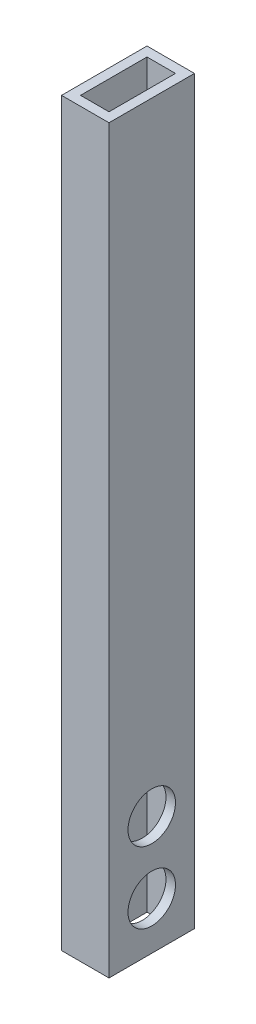
from build123d import *

# Parameters (mm, degrees)
SKETCH1_W           = 10
SKETCH1_H           = 250
BOSS_EXTRUDE1_DEPTH = 18
SHELL1_T            = -2
SKETCH3_R           = 5
CUT_EXTRUDE2_DEPTH  = 10
SKETCH4_R           = 5
CUT_EXTRUDE3_DEPTH  = 10
SKETCH5_W           = 18
SKETCH5_H           = 94
CUT_EXTRUDE4_DEPTH  = 10


with BuildPart() as part:
    # Sketch1 → Boss-Extrude1 (new body)
    with BuildSketch(Plane.XY):
        Rectangle(SKETCH1_W, SKETCH1_H)
    extrude(amount=BOSS_EXTRUDE1_DEPTH)

    # Shell1
    shell1_openings = [part.faces().sort_by_distance(p)[0] for p in [
        (0, 125, 9),
        (0, -125, 9),
    ]]
    offset(amount=SHELL1_T, openings=shell1_openings, kind=Kind.INTERSECTION)

    # Sketch3 → Cut-Extrude2 (cut)
    with BuildSketch(Plane.ZY.offset(5)):
        with Locations((9, -100)):
            Circle(SKETCH3_R)
    extrude(amount=-CUT_EXTRUDE2_DEPTH, mode=Mode.SUBTRACT)

    # Sketch4 → Cut-Extrude3 (cut)
    with BuildSketch(Plane(origin=(5, 0, 0), x_dir=(0, 0, -1), z_dir=(1, 0, 0))):
        with Locations((-9, -115)):
            Circle(SKETCH4_R)
    extrude(amount=-CUT_EXTRUDE3_DEPTH, mode=Mode.SUBTRACT)

    # Sketch5 → Cut-Extrude4 (cut)
    with BuildSketch(Plane(origin=(5, 0, 0), x_dir=(0, 0, -1), z_dir=(1, 0, 0))):
        with Locations((-9, 78)):
            Rectangle(SKETCH5_W, SKETCH5_H)
    extrude(amount=-CUT_EXTRUDE4_DEPTH, mode=Mode.SUBTRACT)


solid = part.part
